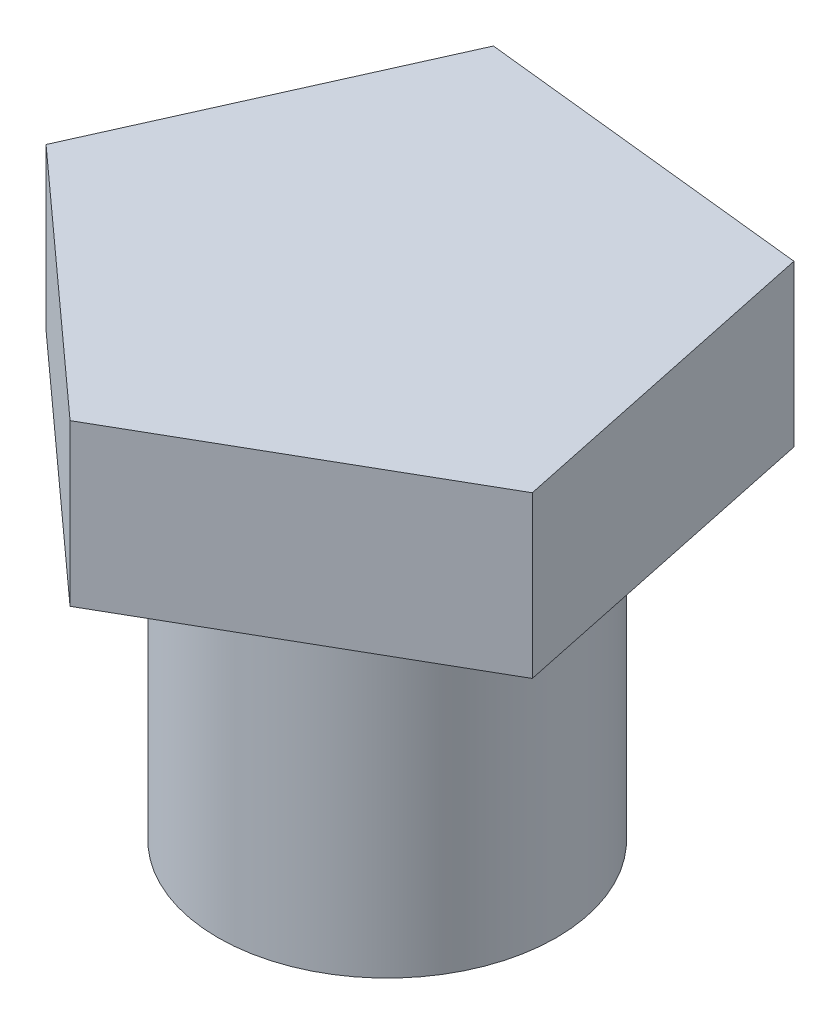
from build123d import *

# Parameters (mm, degrees)
SKETCH1_R           = 5.08
BOSS_EXTRUDE1_DEPTH = 9.906
BOSS_EXTRUDE2_DEPTH = 4.826


with BuildPart() as part:
    # Sketch1 → Boss-Extrude1 (new body)
    with BuildSketch(Plane(origin=(0, 0, 0), x_dir=(1, 0, 0), z_dir=(0, 1, 0))):
        Circle(SKETCH1_R)
    extrude(amount=BOSS_EXTRUDE1_DEPTH)

    # Sketch2 → Boss-Extrude2 (add)
    with BuildSketch(Plane(origin=(0, 9.906, 0), x_dir=(1, 0, 0), z_dir=(0, 1, 0))):
        Polygon((7.887747477, -3.532447537), (5.797005266, 6.410107316), (-4.305001189, 7.49411173), (-8.457642323, -1.778491551), (-0.922109231, -8.593279957), align=None)
    extrude(amount=BOSS_EXTRUDE2_DEPTH)


solid = part.part
